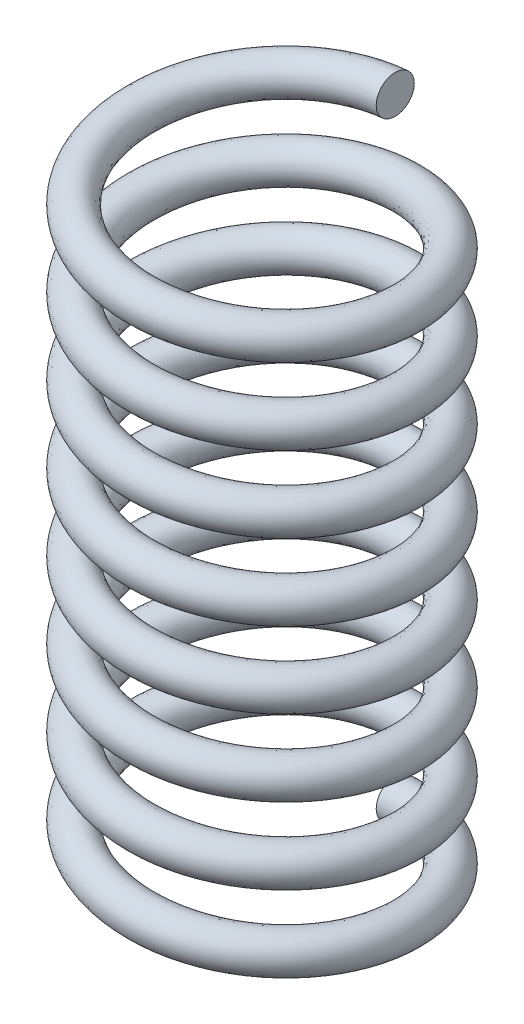
from build123d import *

# Parameters (mm, degrees)
SWEEP3_PITCH       = 20
SWEEP3_HEIGHT      = 160
SWEEP3_RADIUS      = 35
SWEEP3_START_ANGLE = -180
SKETCH5_R          = 5


with BuildPart() as part:
    # Sweep3: sweep along a helix
    with BuildLine() as sweep3_path:
        add(Helix(SWEEP3_PITCH, SWEEP3_HEIGHT, SWEEP3_RADIUS, center=(0, 0, 0), direction=(0, 1, 0), lefthand=True, mode=Mode.PRIVATE).rotate(Axis((0, 0, 0), (0, 1, 0)), SWEEP3_START_ANGLE))
    # Sketch5 → Sweep3 (sweep)
    with BuildSketch(Plane(origin=(0, 0, 0), x_dir=(0, 0, -1), z_dir=(1, 0, 0))):
        with Locations((-34.999942063, 10.000001524)):
            Circle(SKETCH5_R)
    sweep(path=sweep3_path.line, is_frenet=True)


solid = part.part
